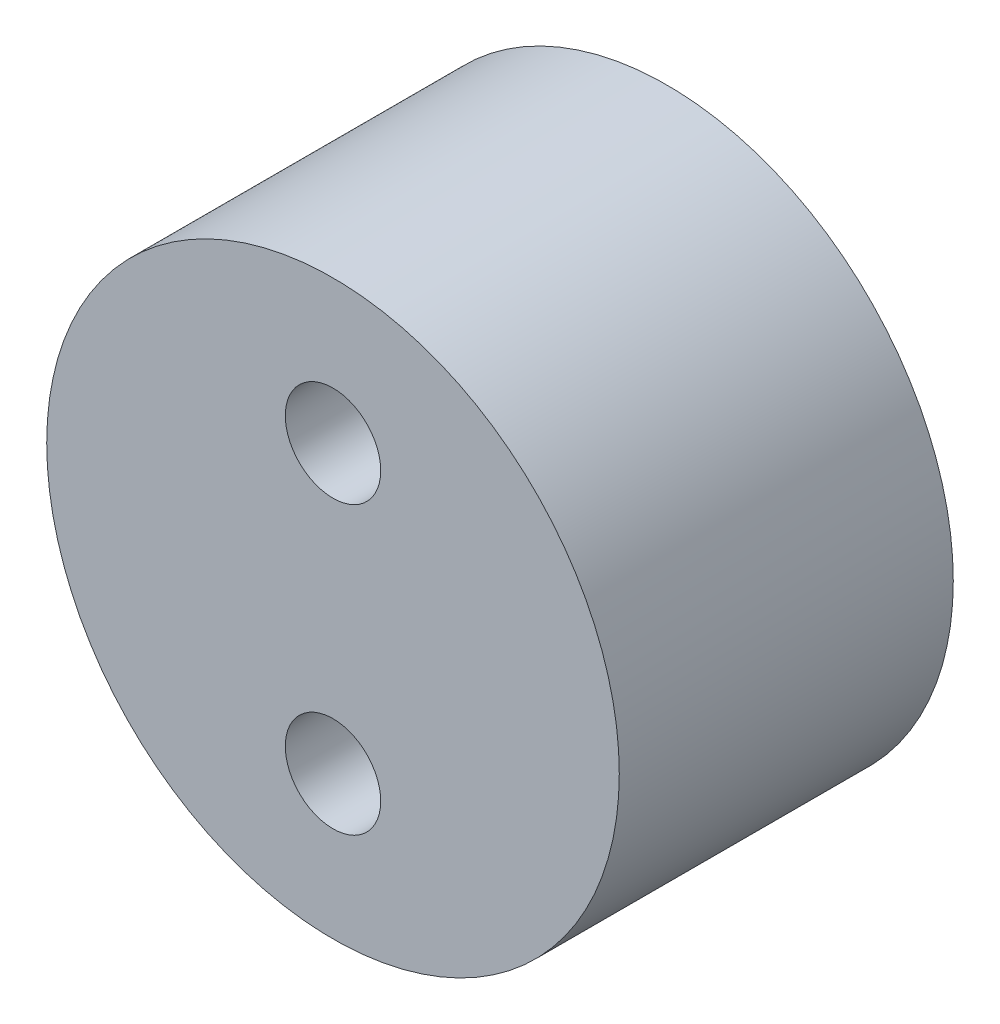
from build123d import *

# Parameters (mm, degrees)
SKETCH1_R           = 15
SKETCH1_R_2         = 2.5
BOSS_EXTRUDE1_DEPTH = 17.5


with BuildPart() as part:
    # Sketch1 → Boss-Extrude1 (new body)
    with BuildSketch(Plane.XY):
        Circle(SKETCH1_R)
        with Locations((0, 7.5)):
            Circle(SKETCH1_R_2, mode=Mode.SUBTRACT)
        with Locations((0, -7.5)):
            Circle(SKETCH1_R_2, mode=Mode.SUBTRACT)
    extrude(amount=BOSS_EXTRUDE1_DEPTH)


solid = part.part
